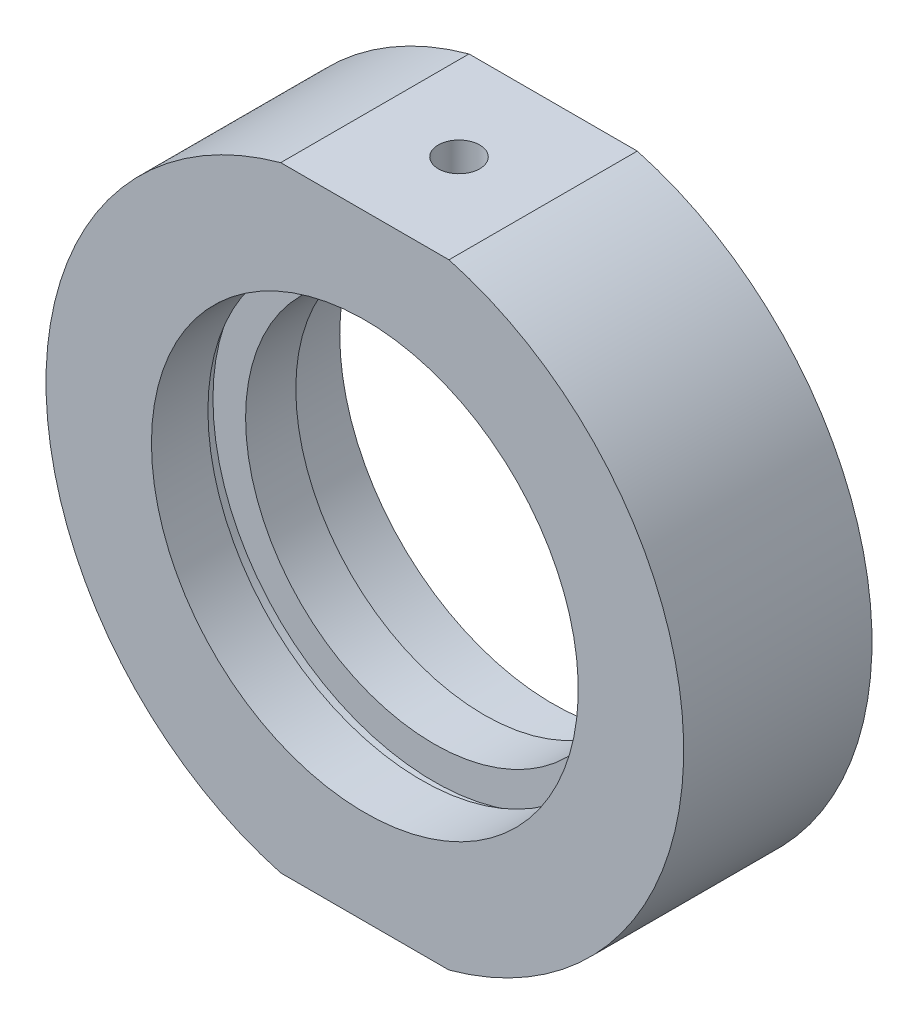
from build123d import *

# Parameters (mm, degrees)
SKETCH_2_W             = 64.02174429
SKETCH_2_H             = 9.248919907
CUT_EXTRUDE_1_DEPTH    = 49
HOLE_WIZARD_M4_2_D     = 3.3
HOLE_WIZARD_M4_2_DEPTH = 5.5
HOLE_WIZARD_M4_2_TIP   = 0.991420021
HOLE_WIZARD_M6_2_D     = 5
HOLE_WIZARD_M6_2_DEPTH = 5.5
HOLE_WIZARD_M6_2_TIP   = 1.502151548


with BuildPart() as part:
    # 草图1 → 旋转1 (revolve)
    with BuildSketch(Plane(origin=(0, 0, 0), x_dir=(1, 0, 0), z_dir=(0, 1, 0)), mode=Mode.PRIVATE) as revolve_1_sk:
        Polygon((25.4, 7.5), (25.4, -7.5), (17, -7.5), (17, -3), (17.6, -3), (17.6, -2), (15, -2), (15, 2), (17.6, 2), (17.6, 3), (17, 3), (17, 7.5), align=None)
    revolve(revolve_1_sk.sketch.rotate(Axis((0, 0, -31.9390681), (0, 0, 1)), 180), axis=Axis((0, 0, -31.9390681), (0, 0, 1)))  # turned: the seam where the file's is

    # 草图2 → 切除-拉伸1 (cut)
    with BuildSketch(Plane.XY.offset(7.5)):
        with Locations((-1.141100508, 29.124459954)):
            Rectangle(SKETCH_2_W, SKETCH_2_H)
        with Locations((-1.141100508, -29.124459954)):
            Rectangle(SKETCH_2_W, SKETCH_2_H)
    extrude(amount=-CUT_EXTRUDE_1_DEPTH, mode=Mode.SUBTRACT)

    # M4 螺纹孔2
    with Locations(Plane(origin=(0, 24.5, 0), x_dir=(1, 0, 0), z_dir=(0, 1, 0))):
        with Locations((0, 0)):
            Hole(HOLE_WIZARD_M4_2_D / 2, depth=HOLE_WIZARD_M4_2_DEPTH)
            with Locations((0, 0, -(HOLE_WIZARD_M4_2_DEPTH + HOLE_WIZARD_M4_2_TIP / 2))):  # 118° drill point
                Cone(0, HOLE_WIZARD_M4_2_D / 2, HOLE_WIZARD_M4_2_TIP, mode=Mode.SUBTRACT)

    # M6 螺纹孔2
    with Locations(Plane(origin=(0, -24.5, 0), x_dir=(-1, 0, 0), z_dir=(0, -1, 0))):
        with Locations((0, 0)):
            Hole(HOLE_WIZARD_M6_2_D / 2, depth=HOLE_WIZARD_M6_2_DEPTH)
            with Locations((0, 0, -(HOLE_WIZARD_M6_2_DEPTH + HOLE_WIZARD_M6_2_TIP / 2))):  # 118° drill point
                Cone(0, HOLE_WIZARD_M6_2_D / 2, HOLE_WIZARD_M6_2_TIP, mode=Mode.SUBTRACT)


solid = part.part
